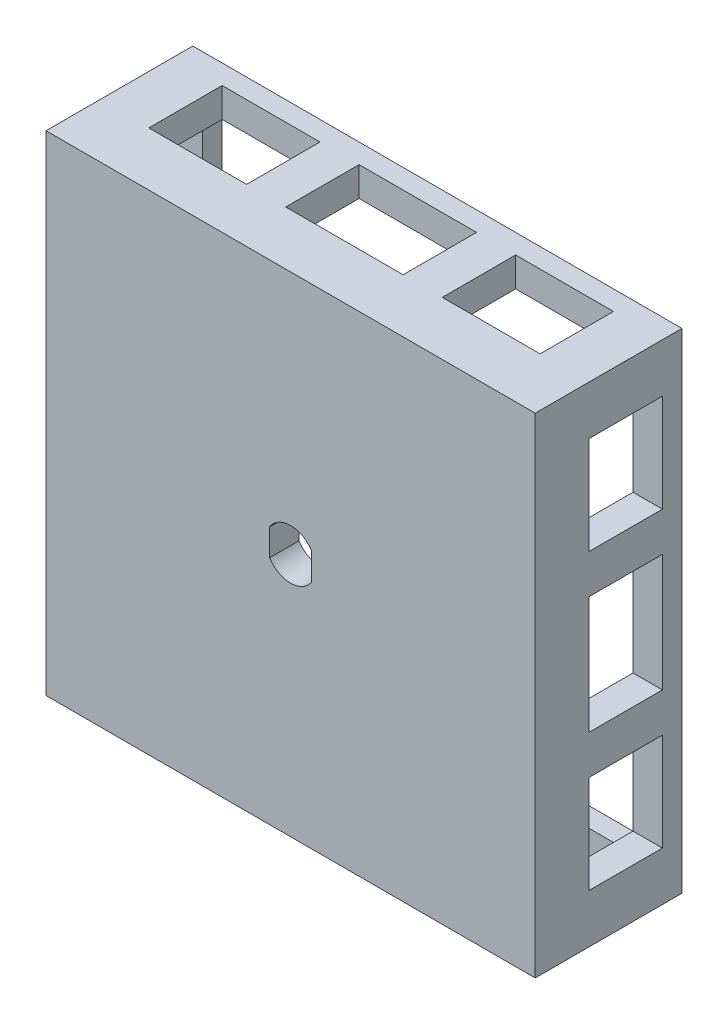
from build123d import *

# Parameters (mm, degrees)
SKETCH1_W               = 50
SKETCH1_H               = 50
BOSS_EXTRUDE1_DEPTH     = 15
SHELL1_T                = -3
CUT_EXTRUDE1_DEPTH      = 1
CUT_EXTRUDE1_DEPTH_BACK = 16
SKETCH5_W               = 7.5
SKETCH5_H               = 10
SKETCH5_H_2             = 12
CUT_EXTRUDE2_DEPTH      = 1
CUT_EXTRUDE2_DEPTH_BACK = 51
SKETCH6_W               = 12
SKETCH6_H               = 7.5
SKETCH6_W_2             = 10
CUT_EXTRUDE3_DEPTH      = 1
CUT_EXTRUDE3_DEPTH_BACK = 51


with BuildPart() as part:
    # Sketch1 → Boss-Extrude1 (new body)
    with BuildSketch(Plane.XY):
        Rectangle(SKETCH1_W, SKETCH1_H)
    extrude(amount=BOSS_EXTRUDE1_DEPTH)

    # Shell1
    shell1_openings = [part.faces().sort_by_distance(p)[0] for p in [
        (0, 0, 0),
    ]]
    offset(amount=SHELL1_T, openings=shell1_openings, kind=Kind.INTERSECTION)

    # Sketch2 → Cut-Extrude1 (cut, two sides)
    with BuildSketch(Plane(origin=(0, 0, 0), x_dir=(-1, 0, 0), z_dir=(0, 0, -1))) as cut_extrude1_sk:
        with BuildLine():
            Line((-2.15, 1.37113092), (-2.15, -1.37113092))
            ThreePointArc((-2.15, -1.37113092), (0, -2.55), (2.15, -1.37113092))
            Line((2.15, -1.37113092), (2.15, 1.37113092))
            ThreePointArc((2.15, 1.37113092), (0, 2.55), (-2.15, 1.37113092))
        make_face()
    extrude(amount=CUT_EXTRUDE1_DEPTH, mode=Mode.SUBTRACT)
    extrude(cut_extrude1_sk.sketch, amount=-CUT_EXTRUDE1_DEPTH_BACK, mode=Mode.SUBTRACT)

    # Sketch5 → Cut-Extrude2 (cut, two sides)
    with BuildSketch(Plane.ZY.offset(25)) as cut_extrude2_sk:
        with Locations((5.75, 15)):
            Rectangle(SKETCH5_W, SKETCH5_H)
        with Locations((5.75, 0)):
            Rectangle(SKETCH5_W, SKETCH5_H_2)
        with Locations((5.75, -15)):
            Rectangle(SKETCH5_W, SKETCH5_H)
    extrude(amount=CUT_EXTRUDE2_DEPTH, mode=Mode.SUBTRACT)
    extrude(cut_extrude2_sk.sketch, amount=-CUT_EXTRUDE2_DEPTH_BACK, mode=Mode.SUBTRACT)

    # Sketch6 → Cut-Extrude3 (cut, two sides)
    with BuildSketch(Plane.XZ.offset(25)) as cut_extrude3_sk:
        with Locations((0, 5.75)):
            Rectangle(SKETCH6_W, SKETCH6_H)
        with Locations((15, 5.75)):
            Rectangle(SKETCH6_W_2, SKETCH6_H)
        with Locations((-15, 5.75)):
            Rectangle(SKETCH6_W_2, SKETCH6_H)
    extrude(amount=CUT_EXTRUDE3_DEPTH, mode=Mode.SUBTRACT)
    extrude(cut_extrude3_sk.sketch, amount=-CUT_EXTRUDE3_DEPTH_BACK, mode=Mode.SUBTRACT)


solid = part.part
